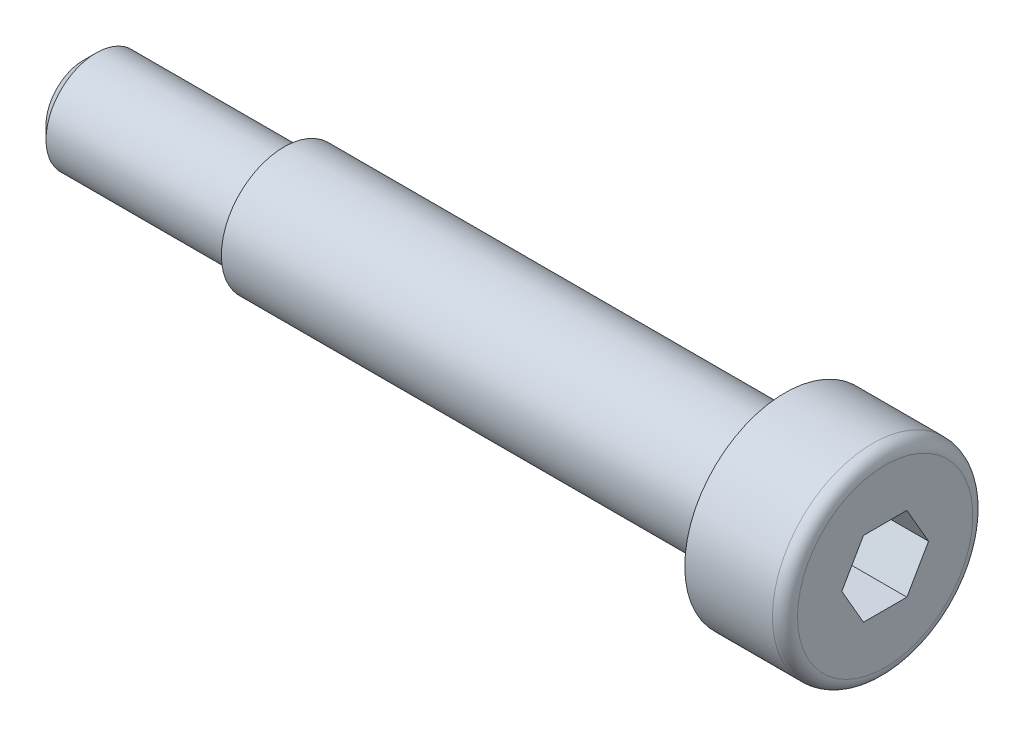
from build123d import *

# Parameters (mm, degrees)
CHAMFER1_SIZE      = 0.5
CUT_EXTRUDE1_DEPTH = 2.4


with BuildPart() as part:
    # Sketch1 → Revolve1 (revolve)
    with BuildSketch(Plane.XY):
        with BuildLine():
            Line((0, 0), (0, 3.5))
            ThreePointArc((0, 3.5), (-0.146446609, 3.853553391), (-0.5, 4))
            Line((-0.5, 4), (-4, 4))
            Line((-4, 4), (-4, 2.5))
            Line((-4, 2.5), (-24, 2.5))
            Line((-24, 2.5), (-24, 2))
            Line((-24, 2), (-32, 2))
            Line((-32, 2), (-32, 0))
            Line((-32, 0), (0, 0))
        make_face()
    revolve(axis=Axis((0, 0, 0), (1, 0, 0)))

    # Chamfer1
    chamfer1_edges = [part.edges().sort_by_distance(p)[0] for p in [
        (-32, -2, 0),
    ]]
    chamfer(chamfer1_edges, length=CHAMFER1_SIZE)

    # Sketch2 → Cut-Extrude1 (cut)
    with BuildSketch(Plane(origin=(0, 0, 0), x_dir=(0, 0, -1), z_dir=(1, 0, 0))):
        Polygon((1.732050808, 0), (0.866025404, 1.5), (-0.866025404, 1.5), (-1.732050808, 0), (-0.866025404, -1.5), (0.866025404, -1.5), align=None)
    extrude(amount=-CUT_EXTRUDE1_DEPTH, mode=Mode.SUBTRACT)


solid = part.part
